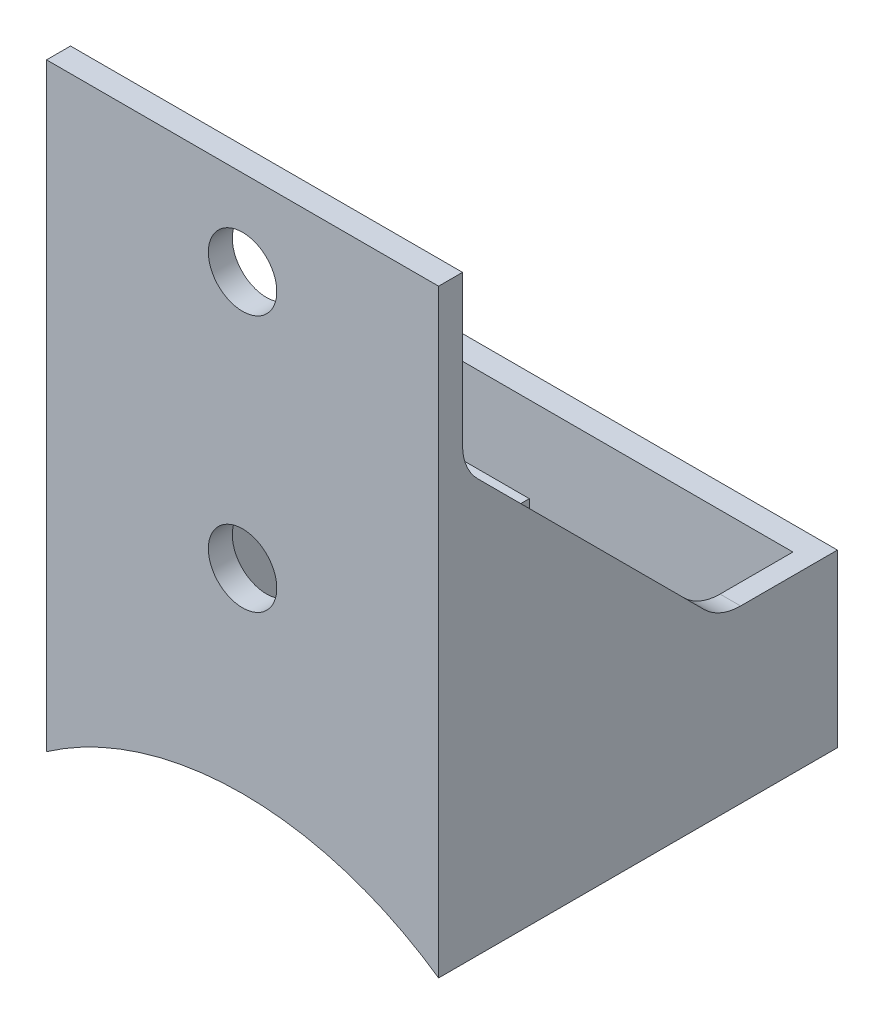
from build123d import *

# Parameters (mm, degrees)
SKETCH_1_W          = 22.9
SKETCH_1_H          = 23.3
SKETCH_1_W_2        = 20.5
SKETCH_1_H_2        = 20.5
EXTRUDE_1_DEPTH     = 10
SKETCH_1_4_R        = 1.27
EXTRUDE_2_DEPTH     = 5
EXTRUDE_3_DEPTH     = 10
SKETCH_3_W          = 22.9
SKETCH_3_H          = 1.4
EXTRUDE_4_DEPTH     = 25
CUT_EXTRUDE_1_REACH = 45.577
SKETCH_4_R          = 20
SKETCH_5_R          = 2
CUT_EXTRUDE_2_DEPTH = 43.84521568
CHAMFER_1_SIZE      = 15
FILLET_1_R          = 3


with BuildPart() as part:
    # 草图1 → 凸台-拉伸1 (new body)
    with BuildSketch(Plane(origin=(0, 0, 0), x_dir=(1, 0, 0), z_dir=(0, 1, 0))):
        Rectangle(SKETCH_1_W, SKETCH_1_H)
        Rectangle(SKETCH_1_W_2, SKETCH_1_H_2, mode=Mode.SUBTRACT)
    extrude(amount=EXTRUDE_1_DEPTH)

    # 草图1<4> → 凸台-拉伸2 (add)
    # profile 1 of 2: a face of its own
    with BuildSketch(Plane(origin=(0, 0, 0), x_dir=(1, 0, 0), z_dir=(0, 1, 0))):
        with BuildLine():
            Line((-5.15, 10.25), (-10.25, 10.25))
            Line((-10.25, 10.25), (-10.25, 5.18))
            Line((-10.25, 5.18), (-7.62, 5.18))
            ThreePointArc((-7.62, 5.18), (-5.87344625, 5.90344625), (-5.15, 7.65))
            Line((-5.15, 7.65), (-5.15, 10.25))
        make_face()
        with Locations((-7.62, 7.65)):
            Circle(SKETCH_1_4_R, mode=Mode.SUBTRACT)
    # profile 2 of 2: a face of its own
    with BuildSketch(Plane(origin=(0, 0, 0), x_dir=(1, 0, 0), z_dir=(0, 1, 0))):
        with BuildLine():
            Line((10.25, 10.25), (5.15, 10.25))
            Line((5.15, 10.25), (5.15, 7.65))
            ThreePointArc((5.15, 7.65), (5.87344625, 5.90344625), (7.62, 5.18))
            Line((7.62, 5.18), (10.25, 5.18))
            Line((10.25, 5.18), (10.25, 10.25))
        make_face()
        with Locations((7.62, 7.65)):
            Circle(SKETCH_1_4_R, mode=Mode.SUBTRACT)
    extrude(amount=EXTRUDE_2_DEPTH)

    # 草图1<5> → 凸台-拉伸3 (add)
    with BuildSketch(Plane(origin=(0, 0, 0), x_dir=(1, 0, 0), z_dir=(0, 1, 0))):
        Polygon((10.25, -10.25), (-10.25, -10.25), (-11.45, -10.25), (-11.45, -11.65), (11.45, -11.65), (11.45, -10.25), align=None)
    extrude(amount=EXTRUDE_3_DEPTH)

    # 草图3 → 凸台-拉伸4 (add)
    with BuildSketch(Plane(origin=(0, 10, 0), x_dir=(1, 0, 0), z_dir=(0, 1, 0))):
        with Locations((0, -10.95)):
            Rectangle(SKETCH_3_W, SKETCH_3_H)
    extrude(amount=EXTRUDE_4_DEPTH)

    # 草图4 → 切除-拉伸1 (cut, up to next)
    with BuildSketch(Plane(origin=(0, 0, -11.65), x_dir=(-1, 0, 0), z_dir=(0, 0, -1)), mode=Mode.PRIVATE) as cut_extrude_1_sk1:
        with Locations((0, -16.398094401)):
            Circle(SKETCH_4_R)
    cut_extrude_1_tool1 = extrude(cut_extrude_1_sk1.sketch, amount=-CUT_EXTRUDE_1_REACH, mode=Mode.PRIVATE) & part.part
    add(cut_extrude_1_tool1.solids().sort_by_distance((0, -16.398094, -11.65))[0], mode=Mode.SUBTRACT)

    # 草图5 → 切除-拉伸2 (cut, through all)
    with BuildSketch(Plane(origin=(0, 0, 10.25), x_dir=(-1, 0, 0), z_dir=(0, 0, -1))):
        with Locations((0, 15)):
            Circle(SKETCH_5_R)
        with Locations((0, 30)):
            Circle(SKETCH_5_R)
    extrude(amount=-CUT_EXTRUDE_2_DEPTH, mode=Mode.SUBTRACT)

    # 倒角1
    chamfer_1_edges = [part.edges().sort_by_distance(p)[0] for p in [
        (10.85, 10, 10.25),
        (-10.85, 10, 10.25),
    ]]
    chamfer(chamfer_1_edges, length=CHAMFER_1_SIZE)

    # 圆角1
    fillet_1_edges = [part.edges().sort_by_distance(p)[0] for p in [
        (10.85, 10, -4.75),
        (10.85, 25, 10.25),
        (-10.85, 25, 10.25),
        (-10.85, 10, -4.75),
    ]]
    fillet(fillet_1_edges, radius=FILLET_1_R)


solid = part.part
